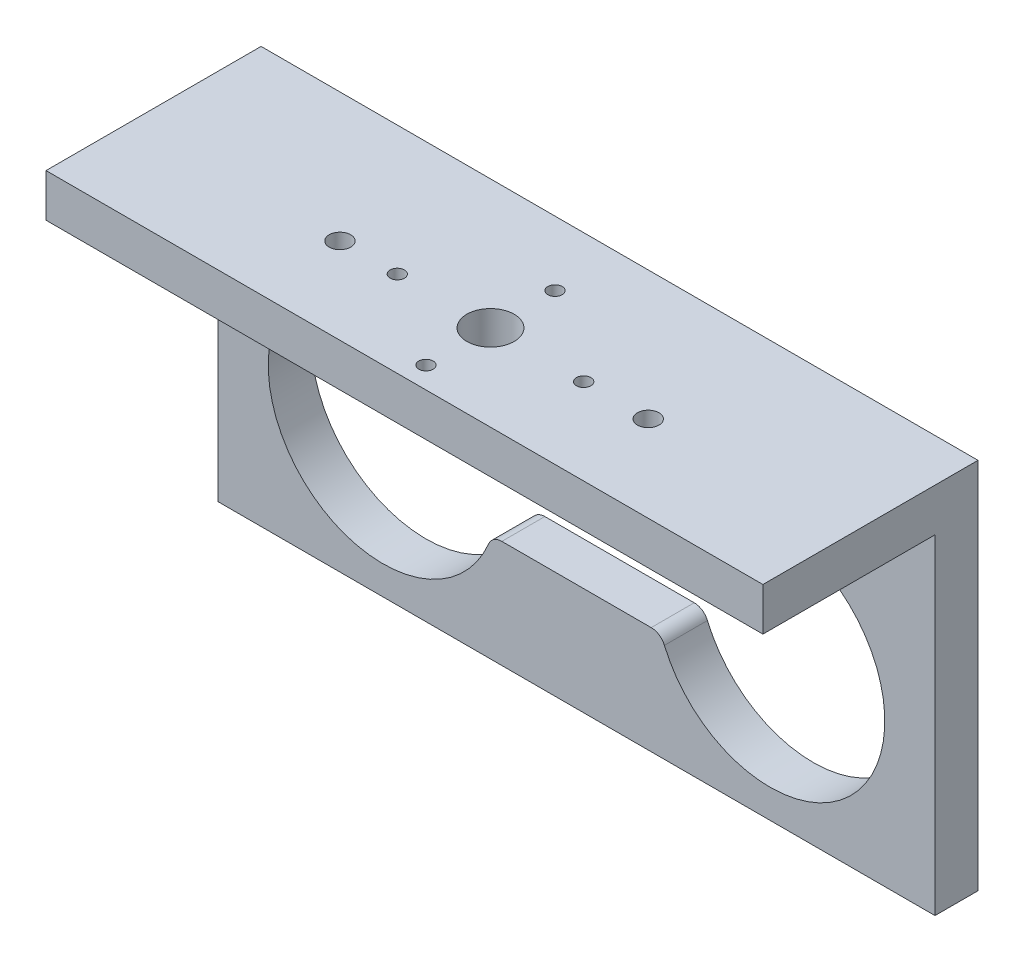
from build123d import *

# Parameters (mm, degrees)
SKETCH_1_W          = 50
SKETCH_1_H          = 20
EXTRUDE_1_DEPTH     = 3
SKETCH_2_W          = 50
SKETCH_2_H          = 15
EXTRUDE_2_DEPTH     = 6
SKETCH_5_W          = 50
SKETCH_5_H          = 12
CUT_EXTRUDE_2_DEPTH = 3
SKETCH_4_R          = 1.65
SKETCH_4_R_2        = 0.5
SKETCH_4_R_3        = 0.75
CUT_EXTRUDE_1_DEPTH = 3


with BuildPart() as part:
    # 草图1 → 凸台-拉伸1 (new body)
    with BuildSketch(Plane.XY):
        Rectangle(SKETCH_1_W, SKETCH_1_H)
        with BuildLine():
            Line((-5.208438024, 2.5), (5.208438024, 2.5))
            ThreePointArc((5.208438024, 2.5), (5.761208823, 2.666666667), (6.129722688, 3.111111111))
            ThreePointArc((6.129722688, 3.111111111), (21.5, 0), (6.129722688, -3.111111111))
            ThreePointArc((6.129722688, -3.111111111), (5.761208823, -2.666666667), (5.208438024, -2.5))
            Line((5.208438024, -2.5), (-5.208438024, -2.5))
            ThreePointArc((-5.208438024, -2.5), (-5.761208823, -2.666666667), (-6.129722688, -3.111111111))
            ThreePointArc((-6.129722688, -3.111111111), (-21.5, 0), (-6.129722688, 3.111111111))
            ThreePointArc((-6.129722688, 3.111111111), (-5.761208823, 2.666666667), (-5.208438024, 2.5))
        make_face(mode=Mode.SUBTRACT)
        with BuildLine():
            Line((3.25, 5.5), (-3.25, 5.5))
            ThreePointArc((-3.25, 5.5), (-5, 7.25), (-3.25, 9))
            Line((-3.25, 9), (3.25, 9))
            ThreePointArc((3.25, 9), (5, 7.25), (3.25, 5.5))
        make_face(mode=Mode.SUBTRACT)
    extrude(amount=EXTRUDE_1_DEPTH)

    # 草图2 → 凸台-拉伸2 (add)
    with BuildSketch(Plane(origin=(0, 10, 0), x_dir=(1, 0, 0), z_dir=(0, 1, 0))):
        with Locations((0, -7.5)):
            Rectangle(SKETCH_2_W, SKETCH_2_H)
    extrude(amount=EXTRUDE_2_DEPTH)

    # 草图5 → 切除-拉伸2 (cut)
    with BuildSketch(Plane.XZ.offset(-10)):
        with Locations((0, 9)):
            Rectangle(SKETCH_5_W, SKETCH_5_H)
    extrude(amount=-CUT_EXTRUDE_2_DEPTH, mode=Mode.SUBTRACT)

    # 草图4 → 切除-拉伸1 (cut)
    with BuildSketch(Plane(origin=(0, 16, 0), x_dir=(1, 0, 0), z_dir=(0, 1, 0))):
        with Locations((0, -9)):
            Circle(SKETCH_4_R)
        with Locations((6.5, -9)):
            Circle(SKETCH_4_R_2)
        with Locations((-6.5, -9)):
            Circle(SKETCH_4_R_2)
        with Locations((11, -9)):
            Circle(SKETCH_4_R_3)
        with Locations((-10.5, -9)):
            Circle(SKETCH_4_R_3)
        with Locations((0, -4.5)):
            Circle(SKETCH_4_R_2)
        with Locations((0, -13.5)):
            Circle(SKETCH_4_R_2)
    extrude(amount=-CUT_EXTRUDE_1_DEPTH, mode=Mode.SUBTRACT)


solid = part.part
